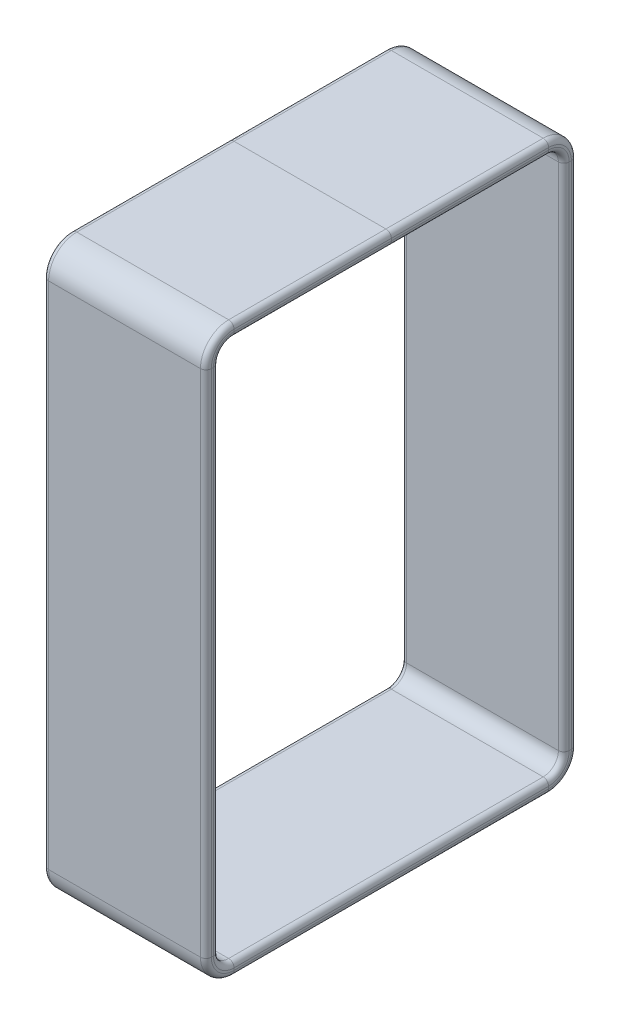
from build123d import *


with BuildPart() as part:
    # Sweep1: sweep along a path in Sketch1
    with BuildLine(Plane(origin=(0, 0, 0), x_dir=(0, 0, -1), z_dir=(1, 0, 0))) as sweep1_path:
        Line((14.5, 25.5), (-14.5, 25.5))
        ThreePointArc((-14.5, 25.5), (-15.914213562, 24.914213562), (-16.5, 23.5))
        Line((-16.5, 23.5), (-16.5, -23.5))
        ThreePointArc((-16.5, -23.5), (-15.914213562, -24.914213562), (-14.5, -25.5))
        Line((-14.5, -25.5), (14.5, -25.5))
        ThreePointArc((14.5, -25.5), (15.914213562, -24.914213562), (16.5, -23.5))
        Line((16.5, -23.5), (16.5, 23.5))
        ThreePointArc((16.5, 23.5), (15.914213562, 24.914213562), (14.5, 25.5))
    # Sketch2 → Sweep1 (sweep)
    with BuildSketch(Plane.XY):
        with BuildLine():
            Line((-7, 26.1), (7, 26.1))
            ThreePointArc((7, 26.1), (7.353553391, 25.953553391), (7.5, 25.6))
            Line((7.5, 25.6), (7.5, 25.4))
            ThreePointArc((7.5, 25.4), (7.353553391, 25.046446609), (7, 24.9))
            Line((7, 24.9), (-7, 24.9))
            ThreePointArc((-7, 24.9), (-7.353553391, 25.046446609), (-7.5, 25.4))
            Line((-7.5, 25.4), (-7.5, 25.6))
            ThreePointArc((-7.5, 25.6), (-7.353553391, 25.953553391), (-7, 26.1))
        make_face()
    sweep(path=sweep1_path.line)


solid = part.part
